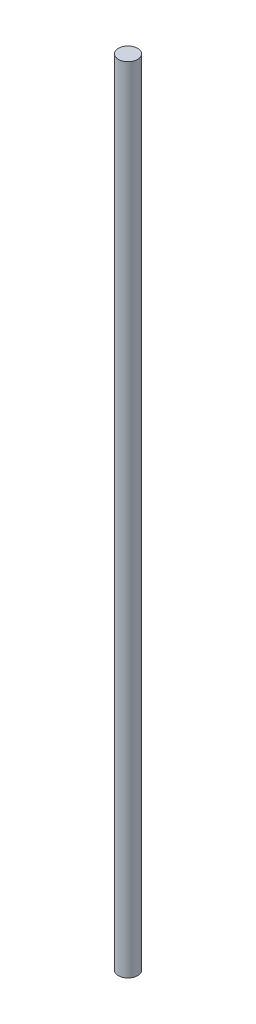
from build123d import *

# Parameters (mm, degrees)
SKETCH_1_W = 4
SKETCH_1_H = 330


with BuildPart() as part:
    # 草图1 → 旋转1 (revolve)
    with BuildSketch(Plane(origin=(0, 0, 0), x_dir=(-1, 0, 0), z_dir=(0, 0, -1))):
        with Locations((-102, -165)):
            Rectangle(SKETCH_1_W, SKETCH_1_H)
    revolve(axis=Axis((100, -330, 0), (0, 1, 0)))


solid = part.part
